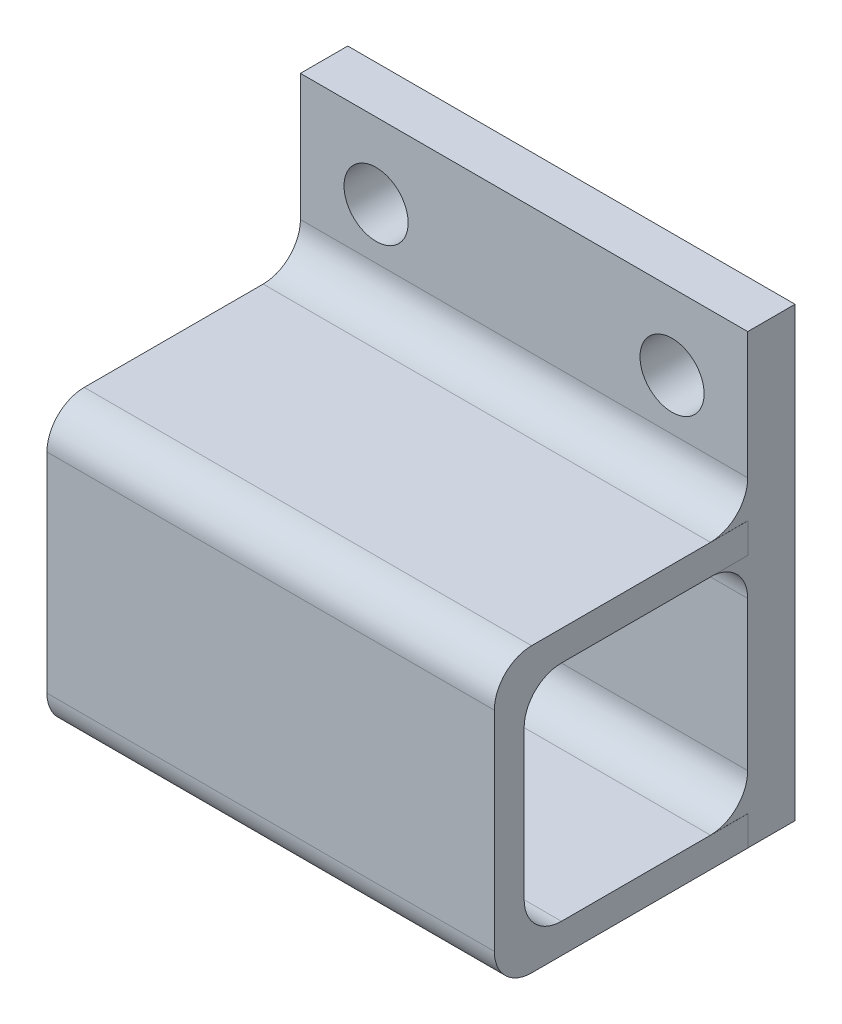
from build123d import *

# Parameters (mm, degrees)
SKETCH1_W           = 30
SKETCH1_H           = 30
SKETCH1_R           = 2.15
BOSS_EXTRUDE1_DEPTH = 3.175
SKETCH2_W           = 30.005666414
SKETCH2_H           = 19.009049167
SKETCH2_W_2         = 23.655666414
SKETCH2_H_2         = 12.659049167
BOSS_EXTRUDE2_DEPTH = 15
SKETCH3_W           = 30.005666414
SKETCH3_H           = 19.009049167
BOSS_EXTRUDE3_DEPTH = 2
SKETCH4_W           = 15
SKETCH4_H           = 15
CUT_EXTRUDE1_DEPTH  = 31.005666414
FILLET1_R           = 2.5


with BuildPart() as part:
    # Sketch1 → Boss-Extrude1 (new body)
    with BuildSketch(Plane.XY):
        Rectangle(SKETCH1_W, SKETCH1_H)
        with Locations((-9.924911661, 9.924911661)):
            Circle(SKETCH1_R, mode=Mode.SUBTRACT)
        with Locations((9.924911661, 9.924911661)):
            Circle(SKETCH1_R, mode=Mode.SUBTRACT)
    extrude(amount=BOSS_EXTRUDE1_DEPTH)

    # Sketch2 → Boss-Extrude2 (add)
    with BuildSketch(Plane.XY.offset(3.175)):
        with Locations((0.002833207, -5.495475417)):
            Rectangle(SKETCH2_W, SKETCH2_H)
        with Locations((0.002833207, -5.495475417)):
            Rectangle(SKETCH2_W_2, SKETCH2_H_2, mode=Mode.SUBTRACT)
    extrude(amount=BOSS_EXTRUDE2_DEPTH)

    # Sketch3 → Boss-Extrude3 (add)
    with BuildSketch(Plane.XY.offset(18.175)):
        with Locations((0.002833207, -5.495475417)):
            Rectangle(SKETCH3_W, SKETCH3_H)
    extrude(amount=BOSS_EXTRUDE3_DEPTH)

    # Sketch4 → Cut-Extrude1 (cut, through all)
    with BuildSketch(Plane.ZY.offset(15)):
        with Locations((10.675, -5.5)):
            Rectangle(SKETCH4_W, SKETCH4_H)
    extrude(amount=-CUT_EXTRUDE1_DEPTH, mode=Mode.SUBTRACT)

    # Fillet1
    fillet1_edges = [part.edges().sort_by_distance(p)[0] for p in [
        (0, 4.009049167, 3.175),
        (0.002833207, -15, 20.175),
        (0.002833207, 4.009049167, 20.175),
        (0, -13, 3.175),
        (0, 2, 3.175),
        (0.002833207, 2, 18.175),
        (0.002833207, -13, 18.175),
    ]]
    fillet(fillet1_edges, radius=FILLET1_R)


solid = part.part
